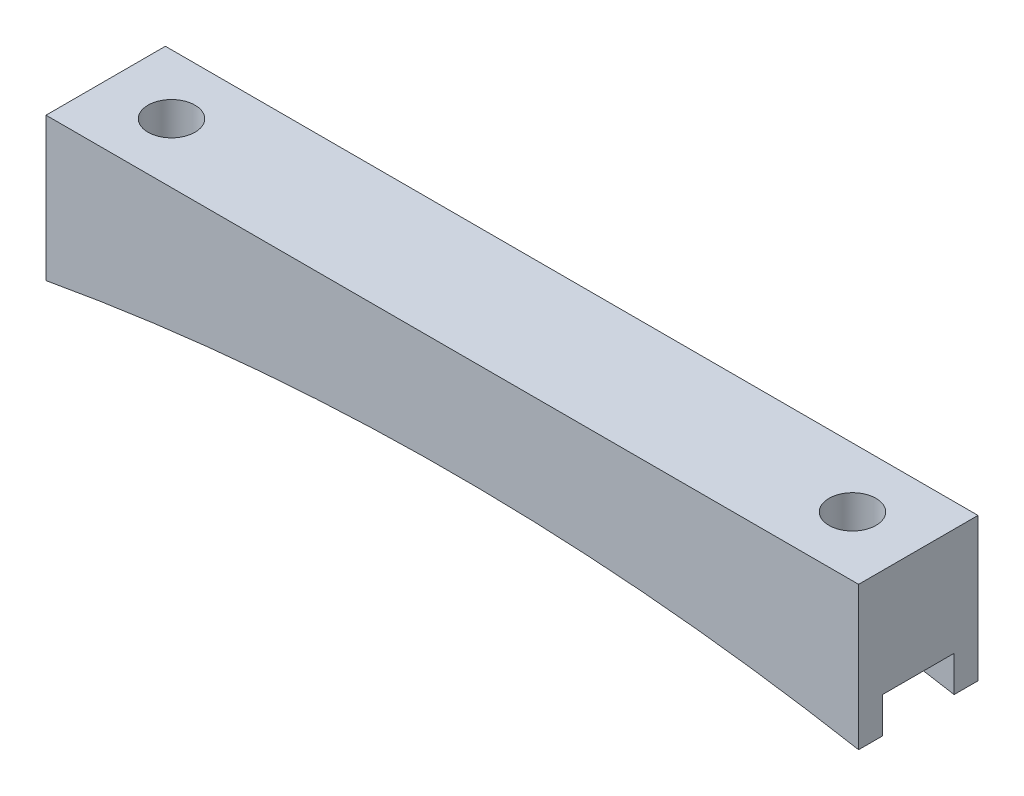
from build123d import *

# Parameters (mm, degrees)
BOSS_EXTRUDE1_DEPTH = 12.7
SKETCH2_R           = 2.5
CUT_EXTRUDE1_DEPTH  = 16.24
SKETCH3_W           = 7.62
SKETCH3_H           = 3.81
CUT_EXTRUDE2_DEPTH  = 87.4400001


with BuildPart() as part:
    # Sketch1 → Boss-Extrude1 (new body)
    with BuildSketch(Plane.XY):
        with BuildLine():
            Line((-43.22, 0), (43.22, 0))
            Line((43.22, 0), (43.22, -15.24))
            ThreePointArc((43.22, -15.24), (0, -11.337812964), (-43.22, -15.24))
            Line((-43.22, -15.24), (-43.22, 0))
        make_face()
    extrude(amount=BOSS_EXTRUDE1_DEPTH)

    # Sketch2 → Cut-Extrude1 (cut, through all)
    with BuildSketch(Plane(origin=(0, 0, 0), x_dir=(1, 0, 0), z_dir=(0, 1, 0))):
        with Locations((-36.22, -6.35)):
            Circle(SKETCH2_R)
        with Locations((36.22, -6.35)):
            Circle(SKETCH2_R)
    extrude(amount=-CUT_EXTRUDE1_DEPTH, mode=Mode.SUBTRACT)

    # Sketch3 → Cut-Extrude2 (cut, through all)
    with BuildSketch(Plane(origin=(43.22, 0, 0), x_dir=(0, 0, -1), z_dir=(1, 0, 0))):
        with Locations((-6.35, -13.335)):
            Rectangle(SKETCH3_W, SKETCH3_H)
    extrude(amount=-CUT_EXTRUDE2_DEPTH, mode=Mode.SUBTRACT)


solid = part.part
